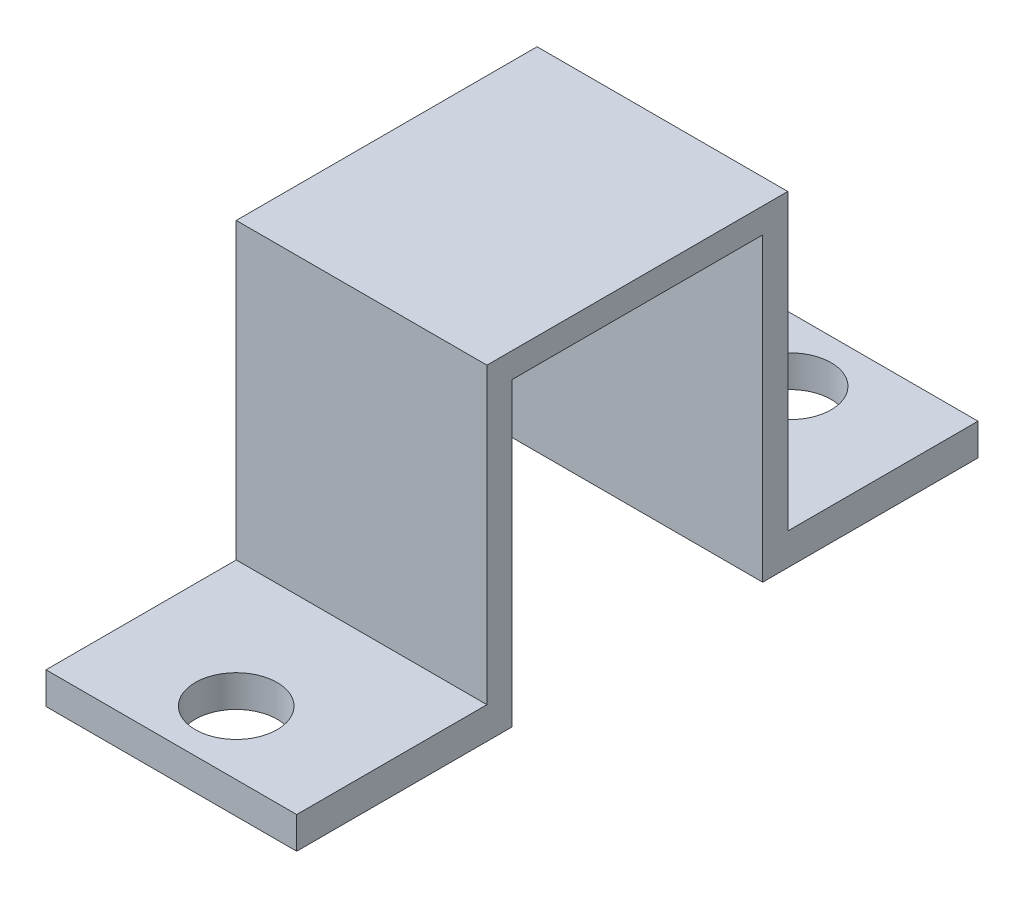
from build123d import *

# Parameters (mm, degrees)
BOSS_EXTRUDE1_DEPTH          = 10
F_30_0_1285_DIAMETER_HOLE1_D = 3.2639


with BuildPart() as part:
    # Sketch1 → Boss-Extrude1 (new body)
    with BuildSketch(Plane(origin=(0, 0, 0), x_dir=(0, 0, -1), z_dir=(1, 0, 0))):
        Polygon((10.828, 0.032), (2.239, 0.032), (2.239, 1.302), (9.828, 1.302), (9.828, 13.032), (14.543, 13.032), (21.828, 13.032), (21.828, 1.302), (29.417, 1.302), (29.417, 0.032), (20.828, 0.032), (20.828, 12.032), (10.828, 12.032), align=None)
    extrude(amount=BOSS_EXTRUDE1_DEPTH)

    # #30 (0.1285) Diameter Hole1 (through all)
    with Locations(Plane(origin=(5.047, 1.302, -26.877), x_dir=(0, 0, 1), z_dir=(0, 1, 0))):
        with Locations((0, 0), (22.098, 0)):
            Hole(F_30_0_1285_DIAMETER_HOLE1_D / 2)


solid = part.part
